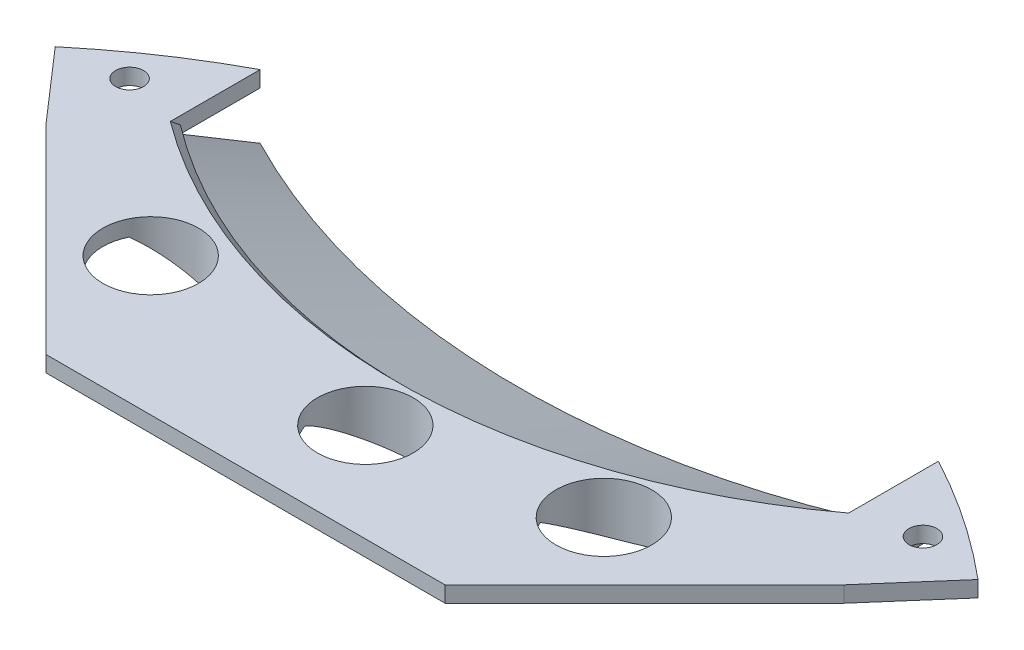
from build123d import *

# Parameters (mm, degrees)
SKETCH1_R               = 90
BOSS_EXTRUDE1_DEPTH     = 2
CUT_EXTRUDE2_DEPTH      = 128.294933128
SKETCH9_R               = 1.75
CUT_EXTRUDE7_DEPTH      = 128.294933128
CUT_EXTRUDE8_DEPTH      = 128.294933128
CUT_EXTRUDE8_DEPTH_BACK = 128.294933128
CHAMFER3_SIZE           = 1
SKETCH17_R              = 6
CUT_EXTRUDE9_DEPTH      = 99.491613961


with BuildPart() as part:
    # Sketch1 → Boss-Extrude1 (new body)
    with BuildSketch(Plane(origin=(0, 0, 0), x_dir=(1, 0, 0), z_dir=(0, 1, 0))):
        with Locations(Location((0, 0, 0), (0, 0, 270))):
            Circle(SKETCH1_R)
    extrude(amount=BOSS_EXTRUDE1_DEPTH)

    # Sketch4 → Cut-Extrude2 (cut, through all)
    with BuildSketch(Plane(origin=(0, 2, 0), x_dir=(1, 0, 0), z_dir=(0, 1, 0))):
        with BuildLine():
            Line((-42.5, 79.333158263), (-42.5, 69.333158263))
            ThreePointArc((-42.5, 69.333158263), (0, 55), (42.5, 69.333158263))
            Line((42.5, 69.333158263), (42.5, 79.333158263))
            Line((42.5, 79.333158263), (42.5, 105.809765059))
            Line((42.5, 105.809765059), (-42.5, 105.809765059))
            Line((-42.5, 105.809765059), (-42.5, 79.333158263))
        make_face()
    extrude(amount=-CUT_EXTRUDE2_DEPTH, mode=Mode.SUBTRACT)

    # Sketch9 → Cut-Extrude7 (cut, through all)
    with BuildSketch(Plane(origin=(0, 2, 0), x_dir=(1, 0, 0), z_dir=(0, 1, 0))):
        with Locations(Location((-49.706440821, 70.180266036, 0), (0, 0, 270))):
            Circle(SKETCH9_R)
    cut_extrude7 = extrude(amount=-CUT_EXTRUDE7_DEPTH, mode=Mode.SUBTRACT)

    # Mirror1: Cut-Extrude7 across plane
    add(cut_extrude7.mirror(Plane(origin=(0, 0, 0), x_dir=(0, 0, 1), z_dir=(1, 0, 0))), mode=Mode.SUBTRACT)

    # Sketch10 → Cut-Extrude8 (cut, two sides)
    with BuildSketch(Plane.XZ) as cut_extrude8_sk:
        Polygon((349.590781265, -403.844847198), (57.81736756, -68.972110366), (50, -60), (25, -35), (-25, -35), (-50, -60), (-57.81736756, -68.972110366), (-349.590781265, -403.844847198), (-349.590781265, 484.460223862), (349.590781265, 484.460223862), align=None)
    extrude(amount=CUT_EXTRUDE8_DEPTH, mode=Mode.SUBTRACT)
    extrude(cut_extrude8_sk.sketch, amount=-CUT_EXTRUDE8_DEPTH_BACK, mode=Mode.SUBTRACT)

    # Sketch15 for Loft1 → Loft1 section 0
    with BuildSketch(Plane(origin=(0, -6, 0), x_dir=(1, 0, 0), z_dir=(0, 1, 0))):
        with BuildLine():
            Line((-42.5, 69.333158263), (-42.5, 79.333158263))
            # circular arc as an exact rational Bezier (weights 1, cos(half-angle), 1)
            Bezier((-42.5, 79.333158263), (0, 57.45059928), (42.5, 79.333158263), weights=[1, 0.889071458, 1])
            Line((42.5, 79.333158263), (42.5, 69.333158263))
            Bezier((42.5, 69.333158263), (0, 36.987960736), (-42.5, 69.333158263), weights=[1, 0.795754331, 1])
        make_face()
    # Sketch16 for Loft1 → Loft1 section 1
    with BuildSketch(Plane.XZ):
        with BuildLine():
            Line((-45.948502669, -63.851980058), (-42.5, -69.333158263))
            Bezier((-42.5, -69.333158263), (0, -36.987960736), (42.5, -69.333158263), weights=[1, 0.795754331, 1])
            Line((42.5, -69.333158263), (44.152042302, -63.851980058))
            Bezier((44.152042302, -63.851980058), (-0.898230184, -19.650095816), (-45.948502669, -63.851980058), weights=[1, 0.713795953, 1])
        make_face()
    loft()

    # Chamfer3
    chamfer3_edges = [part.edges().sort_by_distance(p)[0] for p in [
        (0, 2, -55),
    ]]
    chamfer(chamfer3_edges, length=CHAMFER3_SIZE)

    # Sketch17 → Cut-Extrude9 (cut, through all)
    with BuildSketch(Plane(origin=(0, 2, 0), x_dir=(1, 0, 0), z_dir=(0, 1, 0))):
        with Locations(Location((2.697741472, 47.316027374, 0), (0, 0, 270))):
            Circle(SKETCH17_R)
        with Locations(Location((27.628576658, 52.274065286, 0), (0, 0, 270))):
            Circle(SKETCH17_R)
        with Locations(Location((-29.151926102, 52.274065286, 0), (0, 0, 270))):
            Circle(SKETCH17_R)
    extrude(amount=-CUT_EXTRUDE9_DEPTH, mode=Mode.SUBTRACT)


solid = part.part
